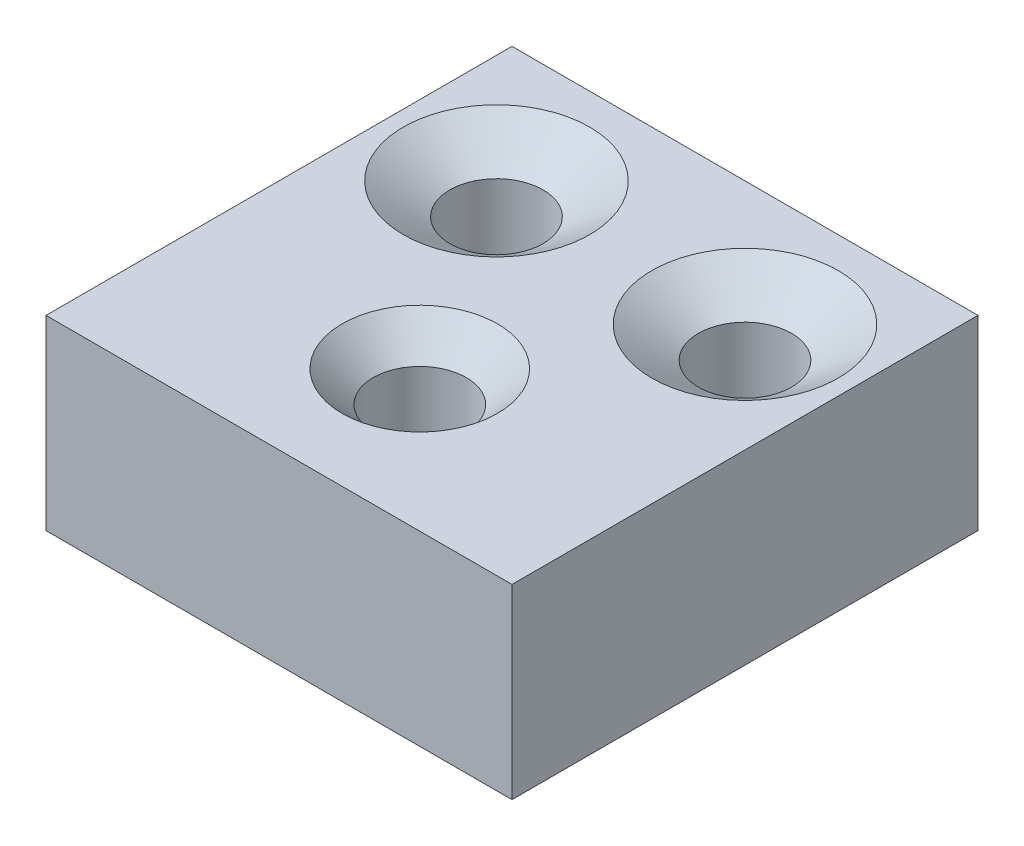
from build123d import *

# Parameters (mm, degrees)
SKETCH1_W           = 150
SKETCH1_H           = 80
BOSS_EXTRUDE1_DEPTH = 60
SKETCH3_W           = 150
SKETCH3_H           = 60
BOSS_EXTRUDE2_DEPTH = 70


with BuildPart() as part:
    # Sketch1 → Boss-Extrude1 (new body)
    with BuildSketch(Plane(origin=(0, 0, 0), x_dir=(1, 0, 0), z_dir=(0, 1, 0))):
        Rectangle(SKETCH1_W, SKETCH1_H)
    extrude(amount=BOSS_EXTRUDE1_DEPTH)

    # Sketch2 → Cut-Revolve1 (revolve, cut)
    with BuildSketch(Plane.XY):
        Polygon((-40, 60), (-70, 60), (-55, 50), (-55, 10), (-40, 10), align=None)
    cut_revolve1 = revolve(axis=Axis((-40, 10, 0), (0, 1, 0)), mode=Mode.SUBTRACT)

    # Mirror1: Cut-Revolve1 across plane
    add(cut_revolve1.mirror(Plane(origin=(0, 0, 0), x_dir=(0, 0, 1), z_dir=(1, 0, 0))), mode=Mode.SUBTRACT)

    # Sketch3 → Boss-Extrude2 (add)
    with BuildSketch(Plane.XY.offset(40)):
        with Locations((0, 30)):
            Rectangle(SKETCH3_W, SKETCH3_H)
    extrude(amount=BOSS_EXTRUDE2_DEPTH)

    # Sketch6 → Cut-Revolve2 (revolve, cut)
    with BuildSketch(Plane(origin=(0, 0, 0), x_dir=(0, 0, -1), z_dir=(1, 0, 0))):
        Polygon((-64.678891041, 60), (-64.678891041, 10), (-79.678891041, 10), (-79.678891041, 50), (-89.678891041, 60), align=None)
    revolve(axis=Axis((0, 60, 64.678891041), (0, -1, 0)), mode=Mode.SUBTRACT)


solid = part.part
